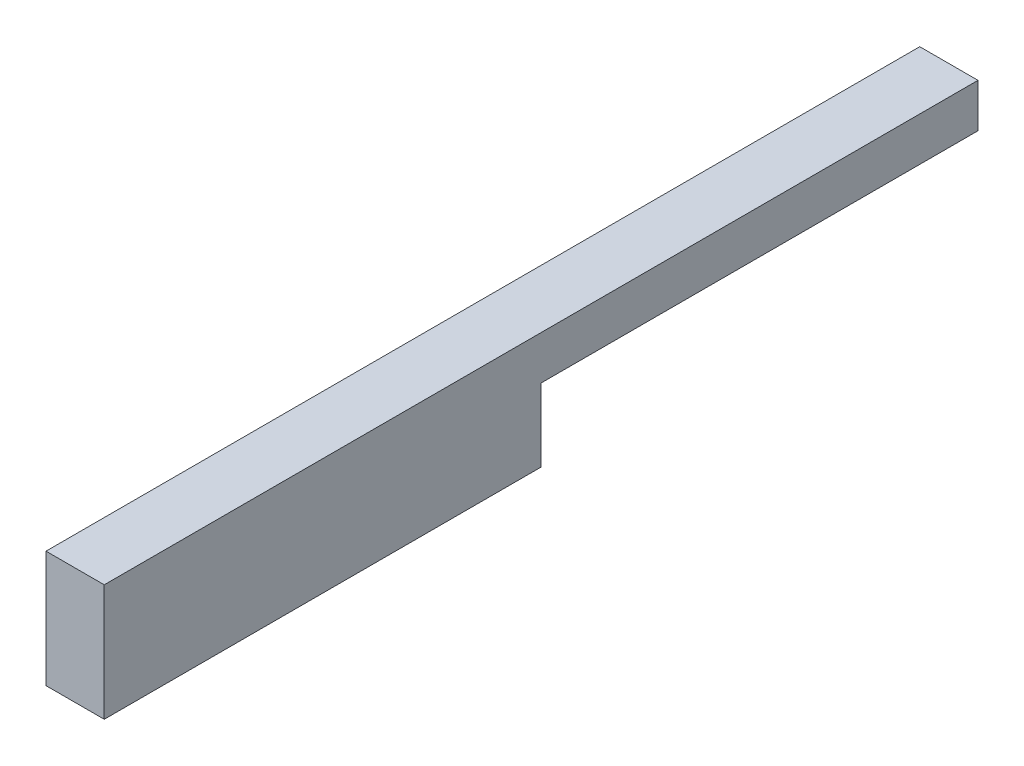
from build123d import *

# Parameters (mm, degrees)
BOSS_EXTRUDE1_DEPTH = 4


with BuildPart() as part:
    # Sketch1 → Boss-Extrude1 (new body)
    with BuildSketch(Plane(origin=(0, 0, 0), x_dir=(0, 0, -1), z_dir=(1, 0, 0))):
        Polygon((-19.986985667, 0.999349283), (-19.986985667, -0.383828287), (-19.986985667, -7.000650717), (10.013014333, -7.000650717), (10.013014333, -2.000650717), (40.013014333, -2.000650717), (40.013014333, 0.999349283), align=None)
    extrude(amount=BOSS_EXTRUDE1_DEPTH)


solid = part.part
